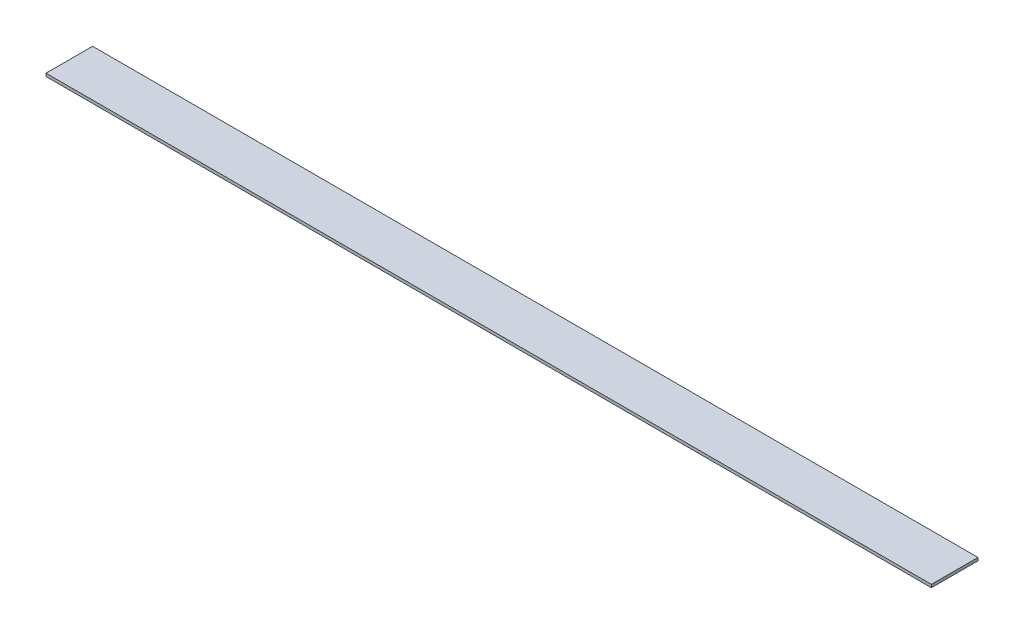
from build123d import *

# Parameters (mm, degrees)
SKETCH1_W           = 482.6
SKETCH1_H           = 25.4
BOSS_EXTRUDE1_DEPTH = 1.5875


with BuildPart() as part:
    # Sketch1 → Boss-Extrude1 (new body)
    with BuildSketch(Plane(origin=(0, 0, 0), x_dir=(1, 0, 0), z_dir=(0, 1, 0))):
        with Locations((241.3, 12.7)):
            Rectangle(SKETCH1_W, SKETCH1_H)
    extrude(amount=BOSS_EXTRUDE1_DEPTH)


solid = part.part
